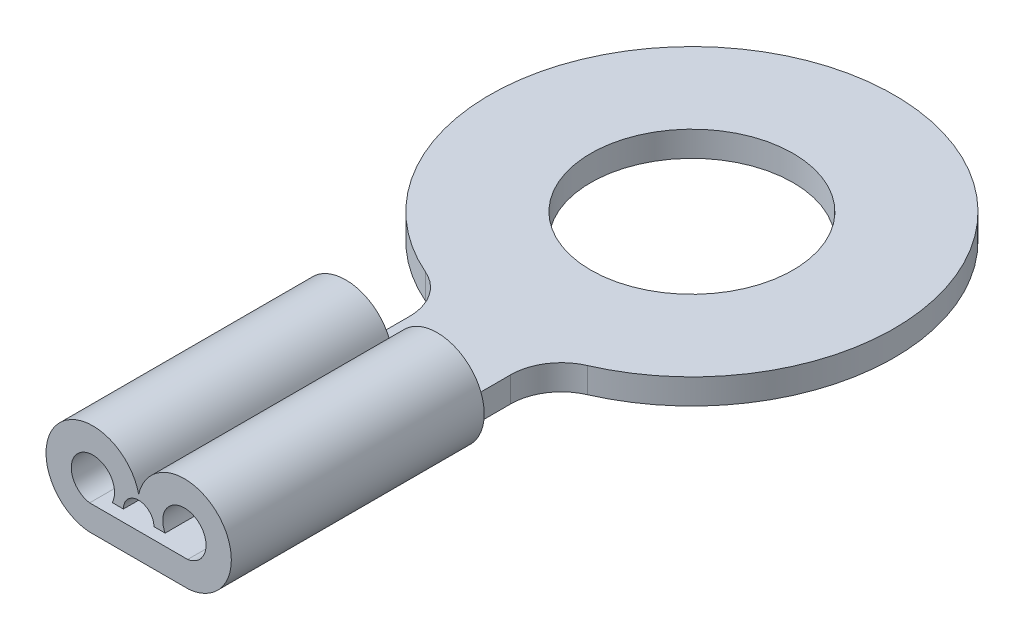
from build123d import *

# Parameters (mm, degrees)
ESQUISSE1_R      = 2
EXTRUSION1_DEPTH = 0.5
EXTRUSION2_DEPTH = 5


with BuildPart() as part:
    # Esquisse1 → Extrusion1 (new body)
    with BuildSketch(Plane(origin=(0, 0, 0), x_dir=(1, 0, 0), z_dir=(0, 1, 0))):
        with BuildLine():
            Line((-1, -10.93878444), (1, -10.93878444))
            Line((1, -10.93878444), (1, -4.582575695))
            ThreePointArc((1, -4.582575695), (1.163339973, -4.034853137), (1.6, -3.666060556))
            ThreePointArc((1.6, -3.666060556), (0, 4), (-1.6, -3.666060556))
            ThreePointArc((-1.6, -3.666060556), (-1.163339973, -4.034853137), (-1, -4.582575695))
            Line((-1, -4.582575695), (-1, -10.93878444))
        make_face()
        with Locations(Location((0, 0, 0), (0, 0, 270))):  # turned: the seam where the file's is
            Circle(ESQUISSE1_R, mode=Mode.SUBTRACT)
    extrude(amount=EXTRUSION1_DEPTH)

    # Esquisse2 → Extrusion2 (add)
    with BuildSketch(Plane.XY.offset(10.93878444)):
        with BuildLine():
            Line((1, 0), (-1, 0))
            ThreePointArc((-1, 0), (-1.599375594, 1.537610938), (0, 1.130798685))
            ThreePointArc((0, 1.130798685), (1.599375594, 1.537610938), (1, 0))
        make_face()
        with BuildLine():
            Line((-0.52344962, 0.727902261), (-0.302000478, 0.727902261))
            ThreePointArc((-0.302000478, 0.727902261), (0, 1.029902739), (0.302000478, 0.727902261))
            Line((0.302000478, 0.727902261), (0.52344962, 0.727902261))
            ThreePointArc((0.52344962, 0.727902261), (1.108344285, 1.299026833), (0.948429699, 0.497333393))
            Line((0.948429699, 0.497333393), (-0.948429699, 0.497333393))
            ThreePointArc((-0.948429699, 0.497333393), (-1.108344285, 1.299026833), (-0.52344962, 0.727902261))
        make_face(mode=Mode.SUBTRACT)
    extrude(amount=-EXTRUSION2_DEPTH)


solid = part.part
